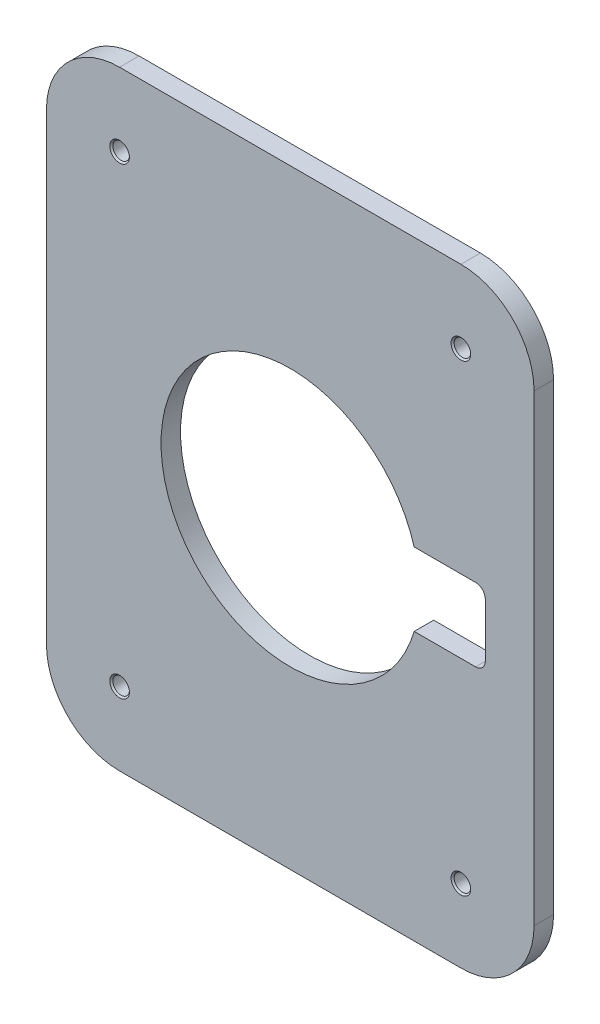
from build123d import *

# Parameters (mm, degrees)
SKIZZE1_W                       = 200
SKIZZE1_H                       = 250
AUFSATZ_LINEAR_AUSTRAGEN1_DEPTH = 8
VERRUNDUNG1_R                   = 30
VERRUNDUNG2_R                   = 4
M8_GEWINDEBOHRUNG1_AT_2_COUNT   = 2
M8_GEWINDEBOHRUNG1_AT_2_PITCH   = 140
M8_GEWINDEBOHRUNG1_AT_3_COUNT   = 2
M8_GEWINDEBOHRUNG1_AT_3_PITCH   = 236.008474424
M8_GEWINDEBOHRUNG1_AT_4_COUNT   = 2
M8_GEWINDEBOHRUNG1_AT_4_PITCH   = 190


with BuildPart() as part:
    # Skizze1 → Aufsatz-Linear austragen1 (new body)
    with BuildSketch(Plane.XY):
        Rectangle(SKIZZE1_W, SKIZZE1_H)
        with BuildLine():
            Line((50.833060109, 15), (80, 15))
            Line((80, 15), (80, -15))
            Line((80, -15), (50.833060109, -15))
            ThreePointArc((50.833060109, -15), (-53, 0), (50.833060109, 15))
        make_face(mode=Mode.SUBTRACT)
    extrude(amount=AUFSATZ_LINEAR_AUSTRAGEN1_DEPTH)

    # Verrundung1
    verrundung1_edges = [part.edges().sort_by_distance(p)[0] for p in [
        (100, -125, 4),
        (-100, -125, 4),
        (-100, 125, 4),
        (100, 125, 4),
    ]]
    fillet(verrundung1_edges, radius=VERRUNDUNG1_R)

    # Verrundung2
    verrundung2_edges = [part.edges().sort_by_distance(p)[0] for p in [
        (80, -15, 4),
        (80, 15, 4),
    ]]
    fillet(verrundung2_edges, radius=VERRUNDUNG2_R)

    # Skizze3 → M8 Gewindebohrung1 (revolve, cut)
    with BuildSketch(Plane(origin=(70, 95, 0), x_dir=(0, 1, 0), z_dir=(1, 0, 0))):
        Polygon((0, 0), (0, 8), (4.025, 8), (3.4, 7.375), (3.4, 0.625), (4.025, 0), align=None)
    m8_gewindebohrung1 = revolve(axis=Axis((70, 95, -6.35), (0, 0, 1)), mode=Mode.SUBTRACT)

    # M8 Gewindebohrung1 at 2: M8 Gewindebohrung1 ×2
    with Locations(*[(-i * M8_GEWINDEBOHRUNG1_AT_2_PITCH, 0, 0) for i in range(1, M8_GEWINDEBOHRUNG1_AT_2_COUNT)]):
        add(m8_gewindebohrung1, mode=Mode.SUBTRACT)

    # M8 Gewindebohrung1 at 3: M8 Gewindebohrung1 ×2
    with Locations(*[Vector(-0.593199038, -0.805055837, 0) * (i * M8_GEWINDEBOHRUNG1_AT_3_PITCH) for i in range(1, M8_GEWINDEBOHRUNG1_AT_3_COUNT)]):
        add(m8_gewindebohrung1, mode=Mode.SUBTRACT)

    # M8 Gewindebohrung1 at 4: M8 Gewindebohrung1 ×2
    with Locations(*[(0, -i * M8_GEWINDEBOHRUNG1_AT_4_PITCH, 0) for i in range(1, M8_GEWINDEBOHRUNG1_AT_4_COUNT)]):
        add(m8_gewindebohrung1, mode=Mode.SUBTRACT)


solid = part.part
